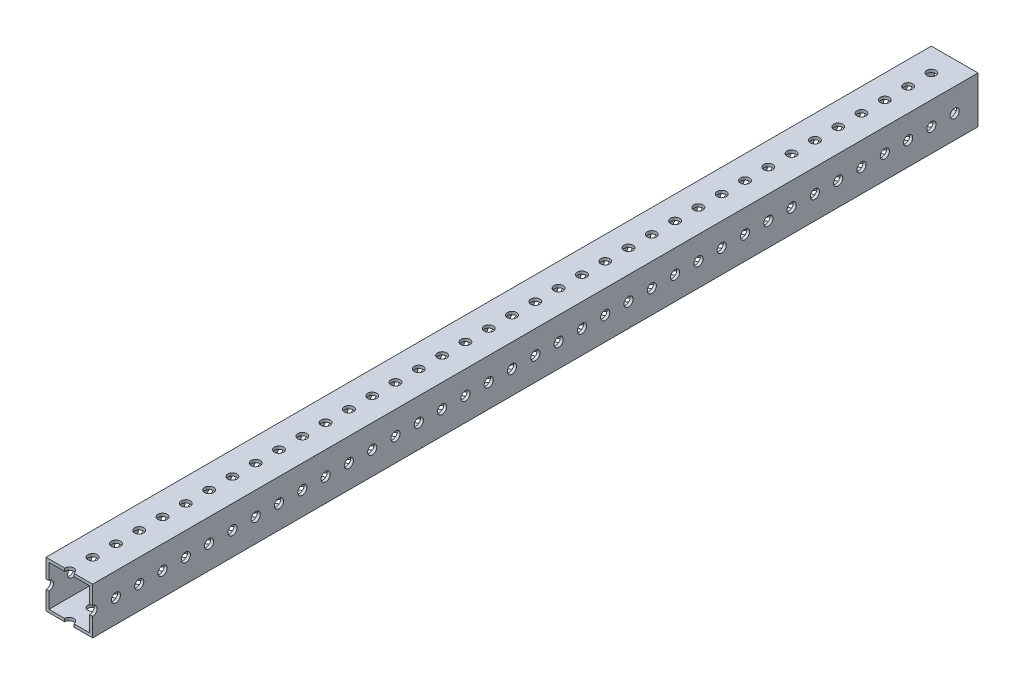
from build123d import *

# Parameters (mm, degrees)
SKETCH1_W           = 25.4
SKETCH1_H           = 25.4
SKETCH1_W_2         = 22.225
SKETCH1_H_2         = 22.225
BOSS_EXTRUDE1_DEPTH = 482.6
SKETCH2_R           = 2.4892
CUT_EXTRUDE1_DEPTH  = 26.4
SKETCH3_R           = 2.4892
CUT_EXTRUDE2_DEPTH  = 26.4


with BuildPart() as part:
    # Sketch1 → Boss-Extrude1 (new body)
    with BuildSketch(Plane.XY):
        with Locations((12.7, 12.7)):
            Rectangle(SKETCH1_W, SKETCH1_H)
        with Locations((12.7, 12.7)):
            Rectangle(SKETCH1_W_2, SKETCH1_H_2, mode=Mode.SUBTRACT)
    extrude(amount=BOSS_EXTRUDE1_DEPTH)

    # Sketch2 → Cut-Extrude1 (cut, through all)
    with BuildSketch(Plane(origin=(0, 25.4, 0), x_dir=(1, 0, 0), z_dir=(0, 1, 0))):
        with Locations((12.7, -12.7)):
            Circle(SKETCH2_R)
        with Locations((12.7, -25.4)):
            Circle(SKETCH2_R)
        with Locations((12.7, -38.1)):
            Circle(SKETCH2_R)
        with Locations((12.7, -50.8)):
            Circle(SKETCH2_R)
        with Locations((12.7, -63.5)):
            Circle(SKETCH2_R)
        with Locations((12.7, -76.2)):
            Circle(SKETCH2_R)
        with Locations((12.7, -88.9)):
            Circle(SKETCH2_R)
        with Locations((12.7, -101.6)):
            Circle(SKETCH2_R)
        with Locations((12.7, -114.3)):
            Circle(SKETCH2_R)
        with Locations((12.7, -127)):
            Circle(SKETCH2_R)
        with Locations((12.7, -139.7)):
            Circle(SKETCH2_R)
        with Locations((12.7, -152.4)):
            Circle(SKETCH2_R)
        with Locations((12.7, -165.1)):
            Circle(SKETCH2_R)
        with Locations((12.7, -177.8)):
            Circle(SKETCH2_R)
        with Locations((12.7, -190.5)):
            Circle(SKETCH2_R)
        with Locations((12.7, -203.2)):
            Circle(SKETCH2_R)
        with Locations((12.7, -215.9)):
            Circle(SKETCH2_R)
        with Locations((12.7, -228.6)):
            Circle(SKETCH2_R)
        with Locations((12.7, -241.3)):
            Circle(SKETCH2_R)
        with Locations((12.7, -254)):
            Circle(SKETCH2_R)
        with Locations((12.7, -266.7)):
            Circle(SKETCH2_R)
        with Locations((12.7, -279.4)):
            Circle(SKETCH2_R)
        with Locations((12.7, -292.1)):
            Circle(SKETCH2_R)
        with Locations((12.7, -304.8)):
            Circle(SKETCH2_R)
        with Locations((12.7, -317.5)):
            Circle(SKETCH2_R)
        with Locations((12.7, -330.2)):
            Circle(SKETCH2_R)
        with Locations((12.7, -342.9)):
            Circle(SKETCH2_R)
        with Locations((12.7, -355.6)):
            Circle(SKETCH2_R)
        with Locations((12.7, -368.3)):
            Circle(SKETCH2_R)
        with Locations((12.7, -381)):
            Circle(SKETCH2_R)
        with Locations((12.7, -393.7)):
            Circle(SKETCH2_R)
        with Locations((12.7, -406.4)):
            Circle(SKETCH2_R)
        with Locations((12.7, -419.1)):
            Circle(SKETCH2_R)
        with Locations((12.7, -431.8)):
            Circle(SKETCH2_R)
        with Locations((12.7, -444.5)):
            Circle(SKETCH2_R)
        with Locations((12.7, -457.2)):
            Circle(SKETCH2_R)
        with Locations((12.7, -469.9)):
            Circle(SKETCH2_R)
        with Locations((12.7, -482.6)):
            Circle(SKETCH2_R)
        with Locations((12.7, -495.3)):
            Circle(SKETCH2_R)
        with Locations((12.7, -508)):
            Circle(SKETCH2_R)
        with Locations((12.7, -520.7)):
            Circle(SKETCH2_R)
        with Locations((12.7, -533.4)):
            Circle(SKETCH2_R)
        with Locations((12.7, -546.1)):
            Circle(SKETCH2_R)
        with Locations((12.7, -558.8)):
            Circle(SKETCH2_R)
    extrude(amount=-CUT_EXTRUDE1_DEPTH, mode=Mode.SUBTRACT)

    # Sketch3 → Cut-Extrude2 (cut, through all)
    with BuildSketch(Plane(origin=(25.4, 0, 0), x_dir=(0, 0, -1), z_dir=(1, 0, 0))):
        with Locations((-12.7, 12.7)):
            Circle(SKETCH3_R)
        with Locations((-25.4, 12.7)):
            Circle(SKETCH3_R)
        with Locations((-38.1, 12.7)):
            Circle(SKETCH3_R)
        with Locations((-50.8, 12.7)):
            Circle(SKETCH3_R)
        with Locations((-63.5, 12.7)):
            Circle(SKETCH3_R)
        with Locations((-76.2, 12.7)):
            Circle(SKETCH3_R)
        with Locations((-88.9, 12.7)):
            Circle(SKETCH3_R)
        with Locations((-101.6, 12.7)):
            Circle(SKETCH3_R)
        with Locations((-114.3, 12.7)):
            Circle(SKETCH3_R)
        with Locations((-127, 12.7)):
            Circle(SKETCH3_R)
        with Locations((-139.7, 12.7)):
            Circle(SKETCH3_R)
        with Locations((-152.4, 12.7)):
            Circle(SKETCH3_R)
        with Locations((-165.1, 12.7)):
            Circle(SKETCH3_R)
        with Locations((-177.8, 12.7)):
            Circle(SKETCH3_R)
        with Locations((-190.5, 12.7)):
            Circle(SKETCH3_R)
        with Locations((-203.2, 12.7)):
            Circle(SKETCH3_R)
        with Locations((-215.9, 12.7)):
            Circle(SKETCH3_R)
        with Locations((-228.6, 12.7)):
            Circle(SKETCH3_R)
        with Locations((-241.3, 12.7)):
            Circle(SKETCH3_R)
        with Locations((-254, 12.7)):
            Circle(SKETCH3_R)
        with Locations((-266.7, 12.7)):
            Circle(SKETCH3_R)
        with Locations((-279.4, 12.7)):
            Circle(SKETCH3_R)
        with Locations((-292.1, 12.7)):
            Circle(SKETCH3_R)
        with Locations((-304.8, 12.7)):
            Circle(SKETCH3_R)
        with Locations((-317.5, 12.7)):
            Circle(SKETCH3_R)
        with Locations((-330.2, 12.7)):
            Circle(SKETCH3_R)
        with Locations((-342.9, 12.7)):
            Circle(SKETCH3_R)
        with Locations((-355.6, 12.7)):
            Circle(SKETCH3_R)
        with Locations((-368.3, 12.7)):
            Circle(SKETCH3_R)
        with Locations((-381, 12.7)):
            Circle(SKETCH3_R)
        with Locations((-393.7, 12.7)):
            Circle(SKETCH3_R)
        with Locations((-406.4, 12.7)):
            Circle(SKETCH3_R)
        with Locations((-419.1, 12.7)):
            Circle(SKETCH3_R)
        with Locations((-431.8, 12.7)):
            Circle(SKETCH3_R)
        with Locations((-444.5, 12.7)):
            Circle(SKETCH3_R)
        with Locations((-457.2, 12.7)):
            Circle(SKETCH3_R)
        with Locations((-469.9, 12.7)):
            Circle(SKETCH3_R)
        with Locations((-482.6, 12.7)):
            Circle(SKETCH3_R)
        with Locations((-495.3, 12.7)):
            Circle(SKETCH3_R)
        with Locations((-508, 12.7)):
            Circle(SKETCH3_R)
        with Locations((-520.7, 12.7)):
            Circle(SKETCH3_R)
        with Locations((-533.4, 12.7)):
            Circle(SKETCH3_R)
        with Locations((-546.1, 12.7)):
            Circle(SKETCH3_R)
        with Locations((-558.8, 12.7)):
            Circle(SKETCH3_R)
    extrude(amount=-CUT_EXTRUDE2_DEPTH, mode=Mode.SUBTRACT)


solid = part.part
